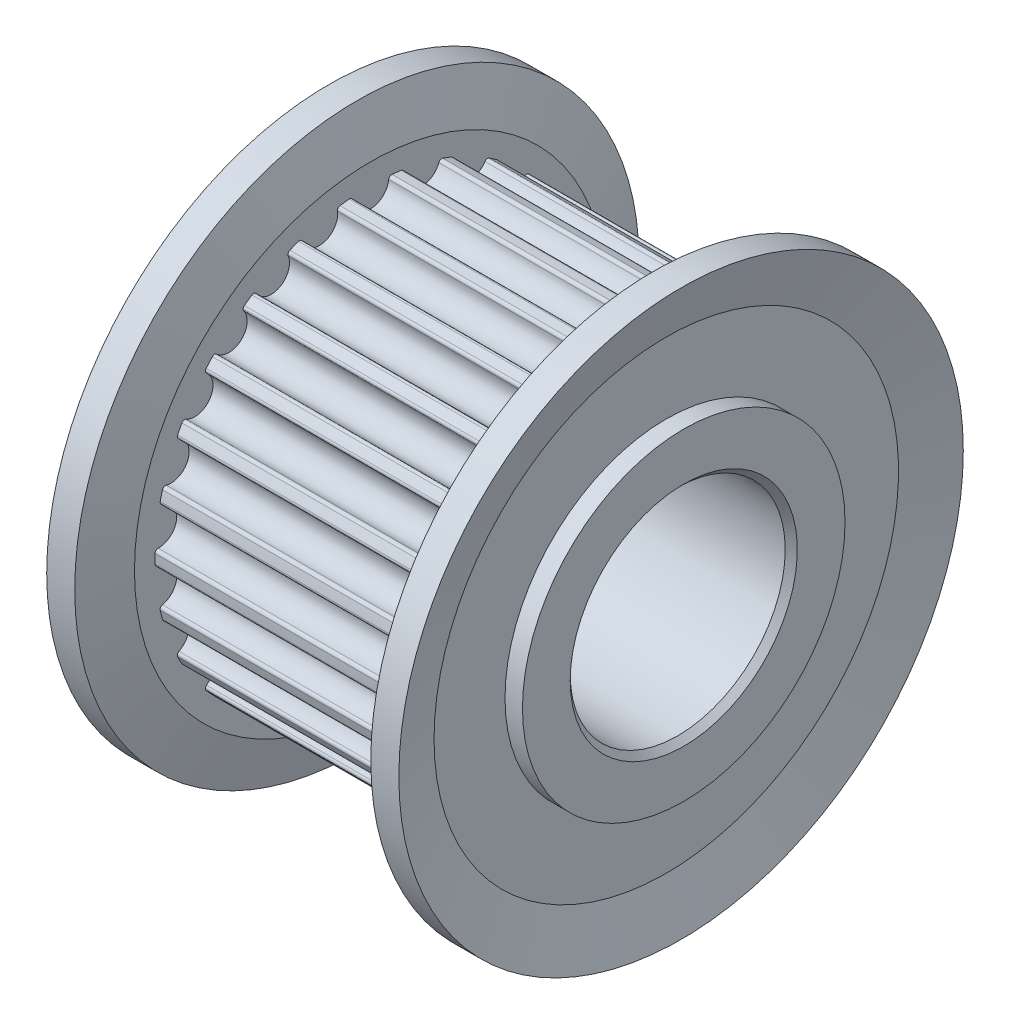
from build123d import *

# Parameters (mm, degrees)
CUT_EXTRUDE1_DEPTH = 33.733366768
CIRPATTERN1_COUNT  = 26


with BuildPart() as part:
    # Sketch1 → Revolve1 (revolve)
    with BuildSketch(Plane.XY):
        Polygon((20.5, 6), (19.85, 6), (19.85, 4.225), (20.075, 4), (32.925, 4), (33.15, 4.225), (33.15, 6), (32.5, 6), (31.5, 6), (31.5, 8.02), (21.5, 8.02), (21.5, 6), align=None)
    revolve(axis=Axis((17.85, 0, 0), (1, 0, 0)))

    # Sketch5 → Cut-Extrude1 (cut, through all)
    with BuildSketch(Plane(origin=(21.5, 0, -21.5), x_dir=(0, 0, 1), z_dir=(-1, 0, 0))):
        with BuildLine():
            Line((19, 7.620393691), (19, 7.888322065))
            ThreePointArc((19, 7.888322065), (21.5, 8.275), (24, 7.888322065))
            Line((24, 7.888322065), (24, 7.620393691))
            ThreePointArc((24, 7.620393691), (23.15727635, 7.846899713), (22.294932233, 7.980506422))
            ThreePointArc((22.294932233, 7.980506422), (22.212418714, 7.955529493), (22.171812608, 7.879480351))
            ThreePointArc((22.171812608, 7.879480351), (21.5, 7.26999997), (20.828187392, 7.879480351))
            ThreePointArc((20.828187392, 7.879480351), (20.787581286, 7.955529493), (20.705067767, 7.980506422))
            ThreePointArc((20.705067767, 7.980506422), (19.84272365, 7.846899713), (19, 7.620393691))
        make_face()
    cut_extrude1 = extrude(amount=-CUT_EXTRUDE1_DEPTH, mode=Mode.SUBTRACT)

    # CirPattern1: Cut-Extrude1 ×26 about axis
    cirpattern1_axis = Axis((17.85, 0, 0), (-1, 0, 0))
    for i in range(1, CIRPATTERN1_COUNT):
        add(cut_extrude1.rotate(cirpattern1_axis, i * 360 / CIRPATTERN1_COUNT), mode=Mode.SUBTRACT)


with BuildPart() as body_2:
    # Sketch1_4 → Revolve2 (revolve)
    with BuildSketch(Plane.XY):
        Polygon((20.5, 8.64), (20.5, 6), (21.5, 6), (21.5, 8.78475157), (20.992802884, 10.5), (19.95, 10.5), align=None)
        Polygon((31.5, 8.78475157), (31.5, 6), (32.5, 6), (32.5, 8.64), (33.05, 10.5), (32.007197116, 10.5), align=None)
    revolve(axis=Axis((17.85, 0, 0), (1, 0, 0)))


solid = Compound([part.part, body_2.part])
